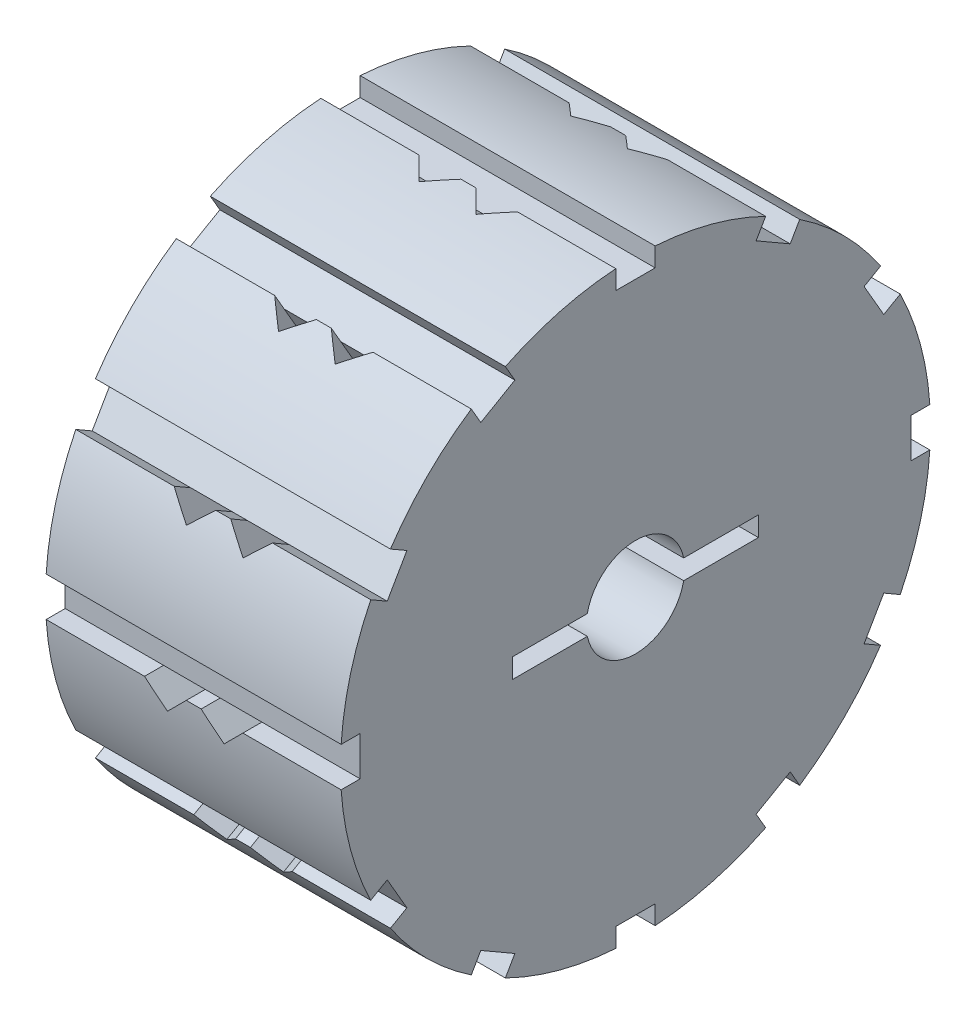
from build123d import *

# Parameters (mm, degrees)
SKETCH_1_R               = 30
EXTRUDE_1_DEPTH          = 30
CUT_EXTRUDE_1_DEPTH      = 52.961524227
CUT_EXTRUDE_2_DEPTH      = 52.961524227
CUT_EXTRUDE_3_DEPTH      = 9
PATTERN_CIRCULAR_2_COUNT = 12


with BuildPart() as part:
    # 草图1 → 凸台-拉伸1 (new body)
    with BuildSketch(Plane(origin=(0, 0, 0), x_dir=(0, 0, -1), z_dir=(1, 0, 0))):
        Circle(SKETCH_1_R)
    extrude(amount=EXTRUDE_1_DEPTH)

    # 草图2 → 切除-拉伸1 (cut, through all)
    with BuildSketch(Plane(origin=(0, 0, 0), x_dir=(0, 0, -1), z_dir=(1, 0, 0))):
        Polygon((0, 30), (2, 30), (2, 28), (-2, 28), (-2, 30), align=None)
    cut_extrude_1 = extrude(amount=CUT_EXTRUDE_1_DEPTH, mode=Mode.SUBTRACT)

    # 草图3 → 切除-拉伸2 (cut, through all)
    with BuildSketch(Plane(origin=(0, 0, 0), x_dir=(0, 0, -1), z_dir=(1, 0, 0))):
        with BuildLine():
            Line((4.898979486, -0.999999998), (12.500084161, -0.999999998))
            Line((12.500084161, -0.999999998), (12.5, 1))
            Line((12.5, 1), (4.898979486, 1))
            ThreePointArc((4.898979486, 1), (0, 5), (-4.898979486, 1))
            Line((-4.898979486, 1), (-12.5, 1))
            Line((-12.5, 1), (-12.499915839, -0.999999998))
            Line((-12.499915839, -0.999999998), (-4.898979486, -0.999999998))
            ThreePointArc((-4.898979486, -0.999999998), (0, -5), (4.898979486, -0.999999998))
        make_face()
    extrude(amount=CUT_EXTRUDE_2_DEPTH, mode=Mode.SUBTRACT)

    # 草图4 → 切除-拉伸3 (cut, symmetric)
    with BuildSketch(Plane(origin=(0, 28, 0), x_dir=(1, 0, 0), z_dir=(0, 1, 0))):
        Polygon((14.249202979, -2), (10.006562292, -2), (12.127882636, -4.121320344), align=None)
        Polygon((15.763921605, -2), (20.006562292, -2), (17.885241949, -4.121320344), align=None)
    cut_extrude_3 = extrude(amount=CUT_EXTRUDE_3_DEPTH, both=True, mode=Mode.SUBTRACT)

    # 阵列(圆周)2: 切除-拉伸1, 切除-拉伸3 ×12 about axis
    pattern_circular_2_axis = Axis((30, 0, 0), (-1, 0, 0))
    add([cut_extrude_1.rotate(pattern_circular_2_axis, i * 360 / PATTERN_CIRCULAR_2_COUNT) for i in range(1, PATTERN_CIRCULAR_2_COUNT)], mode=Mode.SUBTRACT)
    add([cut_extrude_3.rotate(pattern_circular_2_axis, i * 360 / PATTERN_CIRCULAR_2_COUNT) for i in range(1, PATTERN_CIRCULAR_2_COUNT)], mode=Mode.SUBTRACT)


solid = part.part
